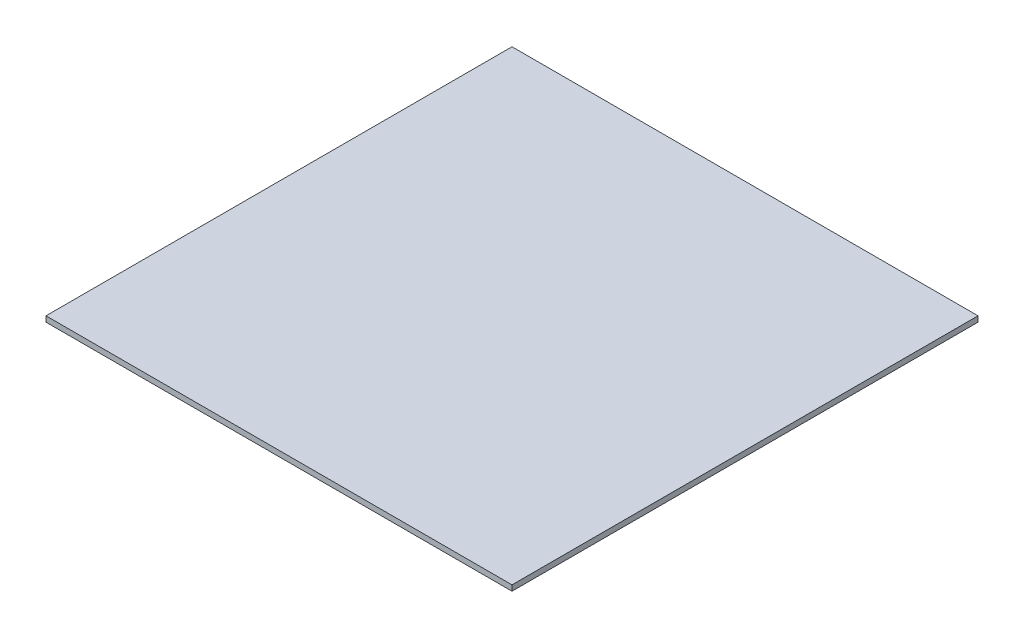
from build123d import *

# Parameters (mm, degrees)
SKETCH1_W           = 133.35
SKETCH1_H           = 133.35
BOSS_EXTRUDE1_DEPTH = 1.5875


with BuildPart() as part:
    # Sketch1 → Boss-Extrude1 (new body)
    with BuildSketch(Plane(origin=(0, 0, 0), x_dir=(1, 0, 0), z_dir=(0, 1, 0))):
        with Locations((66.675, 66.675)):
            Rectangle(SKETCH1_W, SKETCH1_H)
    extrude(amount=BOSS_EXTRUDE1_DEPTH)


solid = part.part
